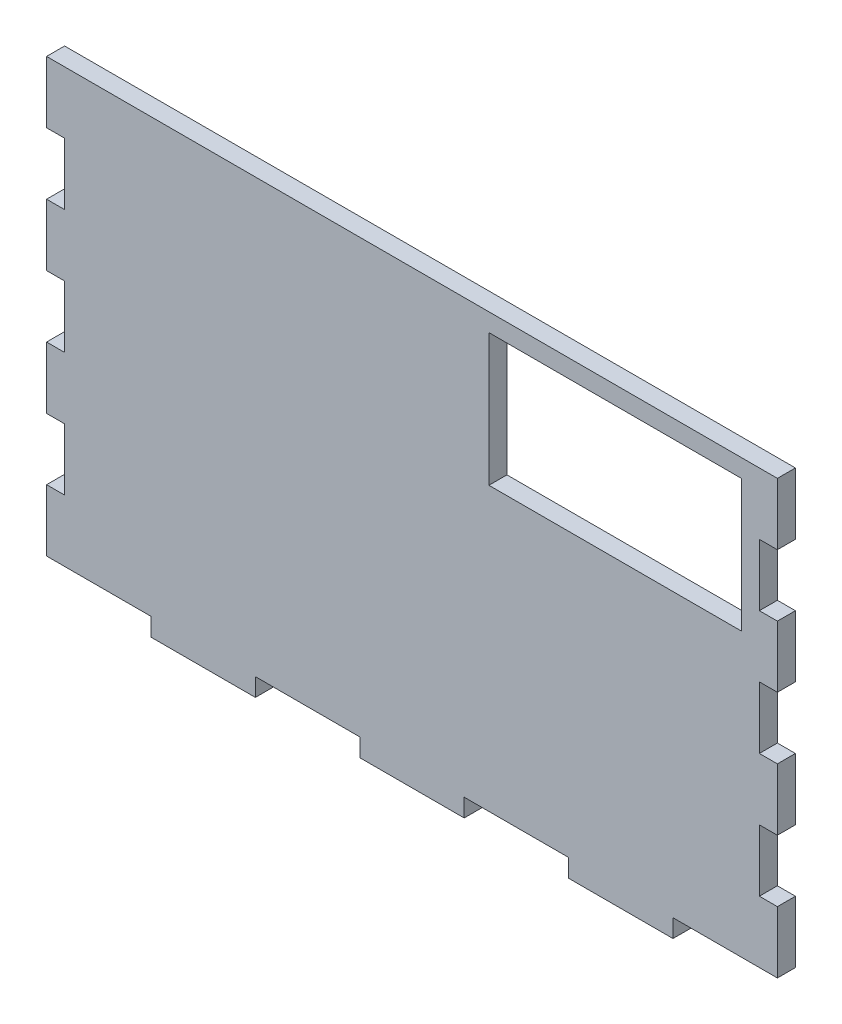
from build123d import *

# Parameters (mm, degrees)
SKETCH1_W           = 121.6
SKETCH1_H           = 72
BOSS_EXTRUDE1_DEPTH = 3
CUT_EXTRUDE1_REACH  = 5
SKETCH4_W           = 42
SKETCH4_H           = 22
SKETCH6_W           = 3
SKETCH6_H           = 10.285714
SKETCH6_H_2         = 10.316450419
SKETCH6_H_3         = 10.26857
SKETCH6_H_4         = 10.29
CUT_EXTRUDE2_DEPTH  = 4
SKETCH7_W           = 17.37142857
SKETCH7_H           = 3
BOSS_EXTRUDE2_DEPTH = 3


with BuildPart() as part:
    # Sketch1 → Boss-Extrude1 (new body)
    with BuildSketch(Plane.XY):
        with Locations((60.8, 36)):
            Rectangle(SKETCH1_W, SKETCH1_H)
    extrude(amount=BOSS_EXTRUDE1_DEPTH)

    # Sketch4 → Cut-Extrude1 (cut, up to next)
    with BuildSketch(Plane.XY.offset(3), mode=Mode.PRIVATE) as cut_extrude1_sk1:
        with Locations((94.6, 58)):
            Rectangle(SKETCH4_W, SKETCH4_H)
    cut_extrude1_tool1 = extrude(cut_extrude1_sk1.sketch, amount=-CUT_EXTRUDE1_REACH, mode=Mode.PRIVATE) & part.part
    add(cut_extrude1_tool1.solids().sort_by_distance((94.6, 58, 3))[0], mode=Mode.SUBTRACT)

    # Sketch6 → Cut-Extrude2 (cut, through all)
    with BuildSketch(Plane.XY.offset(3)):
        with Locations((120.1, 56.571428714)):
            Rectangle(SKETCH6_W, SKETCH6_H)
        with Locations((120.1, 36.015368924)):
            Rectangle(SKETCH6_W, SKETCH6_H_2)
        with Locations((120.1, 15.428572714)):
            Rectangle(SKETCH6_W, SKETCH6_H)
        with Locations((1.5, 15.420000714)):
            Rectangle(SKETCH6_W, SKETCH6_H_3)
        with Locations((1.5, 35.989285714)):
            Rectangle(SKETCH6_W, SKETCH6_H_4)
        with Locations((1.5, 56.569285714)):
            Rectangle(SKETCH6_W, SKETCH6_H_4)
    extrude(amount=-CUT_EXTRUDE2_DEPTH, mode=Mode.SUBTRACT)

    # Sketch7 → Boss-Extrude2 (add)
    with BuildSketch(Plane.XY.offset(3)):
        with Locations((95.542857144, -1.5)):
            Rectangle(SKETCH7_W, SKETCH7_H)
        with Locations((60.800000004, -1.5)):
            Rectangle(SKETCH7_W, SKETCH7_H)
        with Locations((26.057142864, -1.5)):
            Rectangle(SKETCH7_W, SKETCH7_H)
    extrude(amount=-BOSS_EXTRUDE2_DEPTH)


solid = part.part
